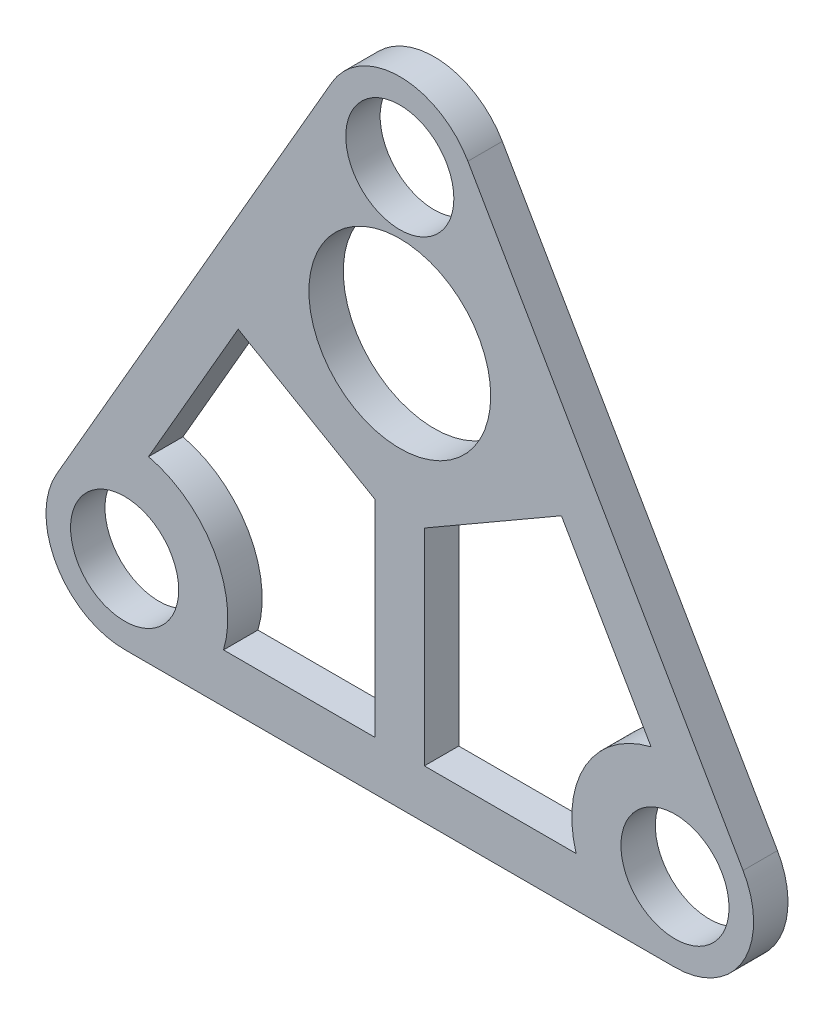
from build123d import *

# Parameters (mm, degrees)
SKETCH1_R           = 11
BOSS_EXTRUDE1_DEPTH = 7
SKETCH3_R           = 18.5
CUT_EXTRUDE1_DEPTH  = 8
CUT_EXTRUDE3_DEPTH  = 8


with BuildPart() as part:
    # Sketch1 → Boss-Extrude1 (new body)
    with BuildSketch(Plane.XY):
        with BuildLine():
            Line((42.143593539, 104.994845224), (-13.856406461, 8))
            ThreePointArc((-13.856406461, 8), (-13.856406461, -8), (0, -16))
            Line((0, -16), (112, -16))
            ThreePointArc((112, -16), (125.856406461, -8), (125.856406461, 8))
            Line((125.856406461, 8), (69.856406461, 104.994845224))
            ThreePointArc((69.856406461, 104.994845224), (56, 112.994845224), (42.143593539, 104.994845224))
        make_face()
        Circle(SKETCH1_R, mode=Mode.SUBTRACT)
        with Locations((112, 0)):
            Circle(SKETCH1_R, mode=Mode.SUBTRACT)
        with Locations((56, 96.994845224)):
            Circle(SKETCH1_R, mode=Mode.SUBTRACT)
    extrude(amount=BOSS_EXTRUDE1_DEPTH)

    # Sketch3 → Cut-Extrude1 (cut, through all)
    with BuildSketch(Plane.XY.offset(7)):
        with Locations((56, 65.944845224)):
            Circle(SKETCH3_R)
    extrude(amount=-CUT_EXTRUDE1_DEPTH, mode=Mode.SUBTRACT)

    # Sketch6 → Cut-Extrude3 (cut, through all)
    with BuildSketch(Plane.XY):
        with BuildLine():
            Line((23.108803184, 52.025621216), (4.866153476, 20.428425058))
            ThreePointArc((4.866153476, 20.428425058), (18.186533479, 10.5), (20.124611797, -6))
            Line((20.124611797, -6), (51, -6))
            Line((51, -6), (51, 35.922631226))
            Line((51, 35.922631226), (23.108803184, 52.025621216))
        make_face()
        with BuildLine():
            Line((61, 35.922631226), (61, -6))
            Line((61, -6), (91.875388203, -6))
            ThreePointArc((91.875388203, -6), (93.813466521, 10.5), (107.133846524, 20.428425058))
            Line((107.133846524, 20.428425058), (88.891196816, 52.025621216))
            Line((88.891196816, 52.025621216), (61, 35.922631226))
        make_face()
    extrude(amount=CUT_EXTRUDE3_DEPTH, mode=Mode.SUBTRACT)


solid = part.part
